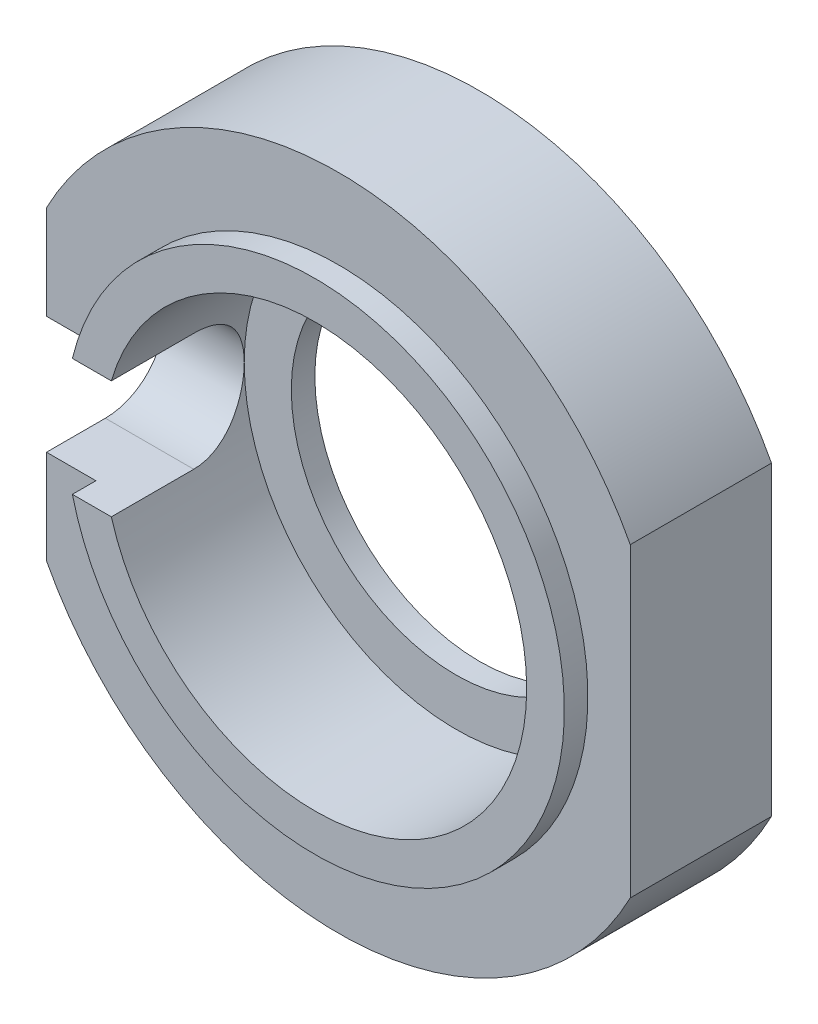
from build123d import *

# Parameters (mm, degrees)
SKETCH_1_R          = 5.3
SKETCH_1_R_2        = 4.5
EXTRUDE_1_DEPTH     = 0.5
SKETCH_1_4_R        = 7
SKETCH_1_4_R_2      = 5.3
SKETCH_1_4_R_3      = 4.5
EXTRUDE_3_DEPTH     = 3
SKETCH_2_R          = 1.25
SKETCH_2_W          = 2.176030001
SKETCH_2_H          = 2.5
CUT_EXTRUDE_2_DEPTH = 8
SKETCH_3_R          = 7
EXTRUDE_4_DEPTH     = 0.5
SKETCH_4_R          = 3.5
CUT_EXTRUDE_3_DEPTH = 4.5000001
SKETCH_5_W          = 7.173185096
SKETCH_5_H          = 25.447728078
SKETCH_5_W_2        = 11.53458805
SKETCH_5_H_2        = 25.700853956
CUT_EXTRUDE_4_DEPTH = 4.5000001


with BuildPart() as part:
    # Sketch 1 → Extrude 1 (new body)
    with BuildSketch(Plane.XY):
        Circle(SKETCH_1_R)
        Circle(SKETCH_1_R_2, mode=Mode.SUBTRACT)
    extrude(amount=EXTRUDE_1_DEPTH)

    # Sketch 1_4 → Extrude 3 (add)
    with BuildSketch(Plane.XY):
        Circle(SKETCH_1_4_R)
        Circle(SKETCH_1_4_R_2, mode=Mode.SUBTRACT)
        Circle(SKETCH_1_4_R_2)
        Circle(SKETCH_1_4_R_3, mode=Mode.SUBTRACT)
    extrude(amount=-EXTRUDE_3_DEPTH)

    # Sketch 2 → Cut-Extrude 2 (cut, through all)
    with BuildSketch(Plane(origin=(0, 0, 0), x_dir=(0, 0, -1), z_dir=(1, 0, 0))):
        with Locations((1.25, 0)):
            Circle(SKETCH_2_R)
        with Locations((0.161984999, 0)):
            Rectangle(SKETCH_2_W, SKETCH_2_H)
    extrude(amount=-CUT_EXTRUDE_2_DEPTH, mode=Mode.SUBTRACT)

    # Sketch 3 → Extrude 4 (add)
    with BuildSketch(Plane(origin=(0, 0, -3), x_dir=(-1, 0, 0), z_dir=(0, 0, -1))):
        with Locations(Location((0, 0, 0), (0, 0, 180))):  # turned: the seam where the file's is
            Circle(SKETCH_3_R)
    extrude(amount=-EXTRUDE_4_DEPTH)

    # Sketch 4 → Cut-Extrude 3 (cut, through all)
    with BuildSketch(Plane(origin=(0, 0, -3), x_dir=(-1, 0, 0), z_dir=(0, 0, -1))):
        Circle(SKETCH_4_R)
    extrude(amount=-CUT_EXTRUDE_3_DEPTH, mode=Mode.SUBTRACT)

    # Sketch 5 → Cut-Extrude 4 (cut, through all)
    with BuildSketch(Plane(origin=(0, 0, -3), x_dir=(-1, 0, 0), z_dir=(0, 0, -1))):
        with Locations((-9.786592548, -0.021348765)):
            Rectangle(SKETCH_5_W, SKETCH_5_H)
        with Locations((11.967294025, -0.783904042)):
            Rectangle(SKETCH_5_W_2, SKETCH_5_H_2)
    extrude(amount=-CUT_EXTRUDE_4_DEPTH, mode=Mode.SUBTRACT)


solid = part.part
